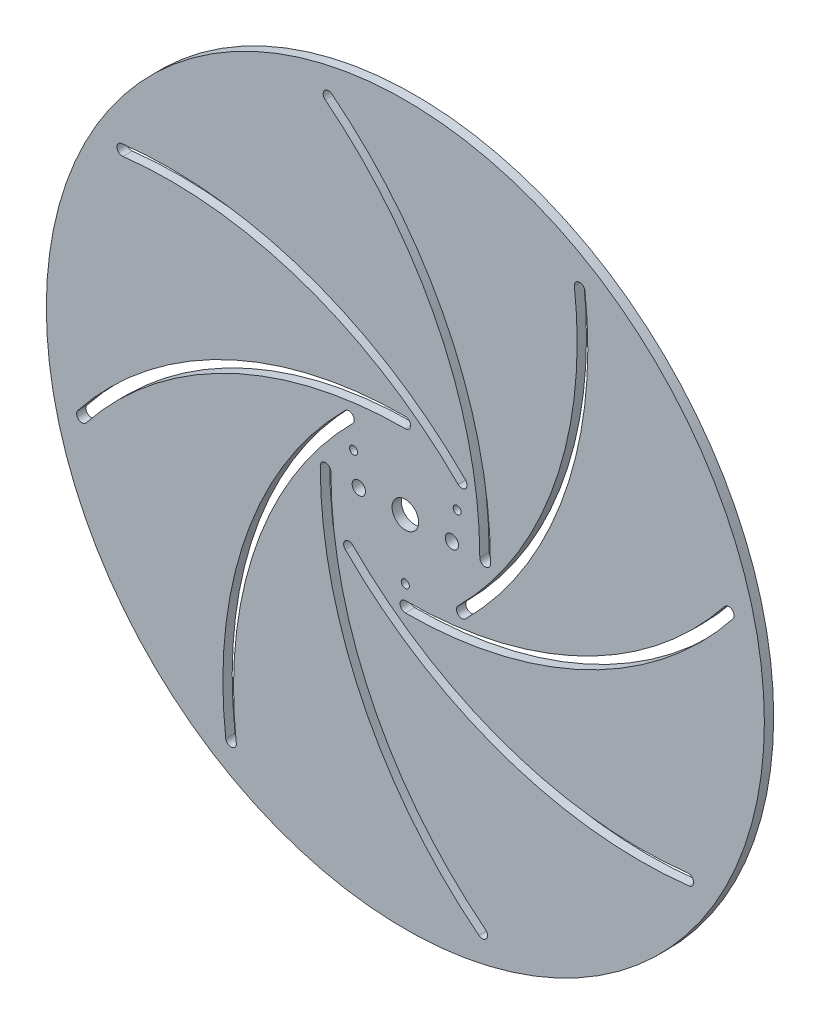
from build123d import *

# Parameters (mm, degrees)
BOSS_EXTRUDE1_DEPTH      = 1.75
BOSS_EXTRUDE1_DEPTH_BACK = 1.75
SKETCH1_R                = 135
SKETCH1_R_2              = 1.5
SKETCH1_R_3              = 2.5


with BuildPart() as part:
    # Sketch1 → Boss-Extrude1 (new, two sides: drawn at the far end of the back side and taken through both)
    with BuildSketch(Plane.XY.offset(-BOSS_EXTRUDE1_DEPTH_BACK)):
        Circle(SKETCH1_R)
        with BuildLine():
            ThreePointArc((-67.544596294, -106.66174343), (-59.916490457, -36.86480939), (-22.627416998, 22.627416998))
            ThreePointArc((-22.627416998, 22.627416998), (-19.798989873, 22.627416998), (-19.798989873, 19.798989873))
            ThreePointArc((-19.798989873, 19.798989873), (-56.138023244, -38.177511002), (-63.571782436, -106.196179206))
            ThreePointArc((-63.571782436, -106.196179206), (-65.325407253, -108.415368247), (-67.544596294, -106.66174343))
        make_face(mode=Mode.SUBTRACT)
        with BuildLine():
            ThreePointArc((27.66, -123.182484144), (-16.3, -68.434713414), (-32, 0))
            ThreePointArc((-32, 0), (-30, 2), (-28, 0))
            ThreePointArc((-28, 0), (-12.7, -66.691153836), (30.14, -120.044076905))
            ThreePointArc((30.14, -120.044076905), (30.46920362, -122.853280525), (27.66, -123.182484144))
        make_face(mode=Mode.SUBTRACT)
        with BuildLine():
            ThreePointArc((106.66174343, -67.544596294), (36.86480939, -59.916490457), (-22.627416998, -22.627416998))
            ThreePointArc((-22.627416998, -22.627416998), (-22.627416998, -19.798989873), (-19.798989873, -19.798989873))
            ThreePointArc((-19.798989873, -19.798989873), (38.177511002, -56.138023244), (106.196179206, -63.571782436))
            ThreePointArc((106.196179206, -63.571782436), (108.415368247, -65.325407253), (106.66174343, -67.544596294))
        make_face(mode=Mode.SUBTRACT)
        with Locations((0, -22.5)):
            Circle(SKETCH1_R_2, mode=Mode.SUBTRACT)
        with Locations((17.5, 0)):
            Circle(SKETCH1_R_3, mode=Mode.SUBTRACT)
        with BuildLine():
            ThreePointArc((123.182484144, 27.66), (68.434713414, -16.3), (0, -32))
            ThreePointArc((0, -32), (-2, -30), (0, -28))
            ThreePointArc((0, -28), (66.691153836, -12.7), (120.044076905, 30.14))
            ThreePointArc((120.044076905, 30.14), (122.853280525, 30.46920362), (123.182484144, 27.66))
        make_face(mode=Mode.SUBTRACT)
        with BuildLine():
            ThreePointArc((-123.182484144, -27.66), (-68.434713414, 16.3), (0, 32))
            ThreePointArc((0, 32), (2, 30), (0, 28))
            ThreePointArc((0, 28), (-66.691153836, 12.7), (-120.044076905, -30.14))
            ThreePointArc((-120.044076905, -30.14), (-122.853280525, -30.46920362), (-123.182484144, -27.66))
        make_face(mode=Mode.SUBTRACT)
        with Locations((-17.5, 0)):
            Circle(SKETCH1_R_3, mode=Mode.SUBTRACT)
        with Locations((-19.485571585, 11.25)):
            Circle(SKETCH1_R_2, mode=Mode.SUBTRACT)
        with BuildLine():
            ThreePointArc((-106.66174343, 67.544596294), (-36.86480939, 59.916490457), (22.627416998, 22.627416998))
            ThreePointArc((22.627416998, 22.627416998), (22.627416998, 19.798989873), (19.798989873, 19.798989873))
            ThreePointArc((19.798989873, 19.798989873), (-38.177511002, 56.138023244), (-106.196179206, 63.571782436))
            ThreePointArc((-106.196179206, 63.571782436), (-108.415368247, 65.325407253), (-106.66174343, 67.544596294))
        make_face(mode=Mode.SUBTRACT)
        with BuildLine():
            ThreePointArc((0.555555556, 4.96903995), (3.726779962, 3.333333333), (5, 0))
            ThreePointArc((5, 0), (-3.354101966, -3.708099244), (-0.5, 4.974937186))
            ThreePointArc((-0.5, 4.974937186), (0.027933838, 4.999921969), (0.555555556, 4.96903995))
        make_face(mode=Mode.SUBTRACT)
        with Locations((19.485571585, 11.25)):
            Circle(SKETCH1_R_2, mode=Mode.SUBTRACT)
        with BuildLine():
            ThreePointArc((-27.66, 123.182484144), (16.3, 68.434713414), (32, 0))
            ThreePointArc((32, 0), (30, -2), (28, 0))
            ThreePointArc((28, 0), (12.7, 66.691153836), (-30.14, 120.044076905))
            ThreePointArc((-30.14, 120.044076905), (-30.46920362, 122.853280525), (-27.66, 123.182484144))
        make_face(mode=Mode.SUBTRACT)
        with BuildLine():
            ThreePointArc((67.544596294, 106.66174343), (59.916490457, 36.86480939), (22.627416998, -22.627416998))
            ThreePointArc((22.627416998, -22.627416998), (19.798989873, -22.627416998), (19.798989873, -19.798989873))
            ThreePointArc((19.798989873, -19.798989873), (56.138023244, 38.177511002), (63.571782436, 106.196179206))
            ThreePointArc((63.571782436, 106.196179206), (65.325407253, 108.415368247), (67.544596294, 106.66174343))
        make_face(mode=Mode.SUBTRACT)
    extrude(amount=BOSS_EXTRUDE1_DEPTH + BOSS_EXTRUDE1_DEPTH_BACK)


solid = part.part
